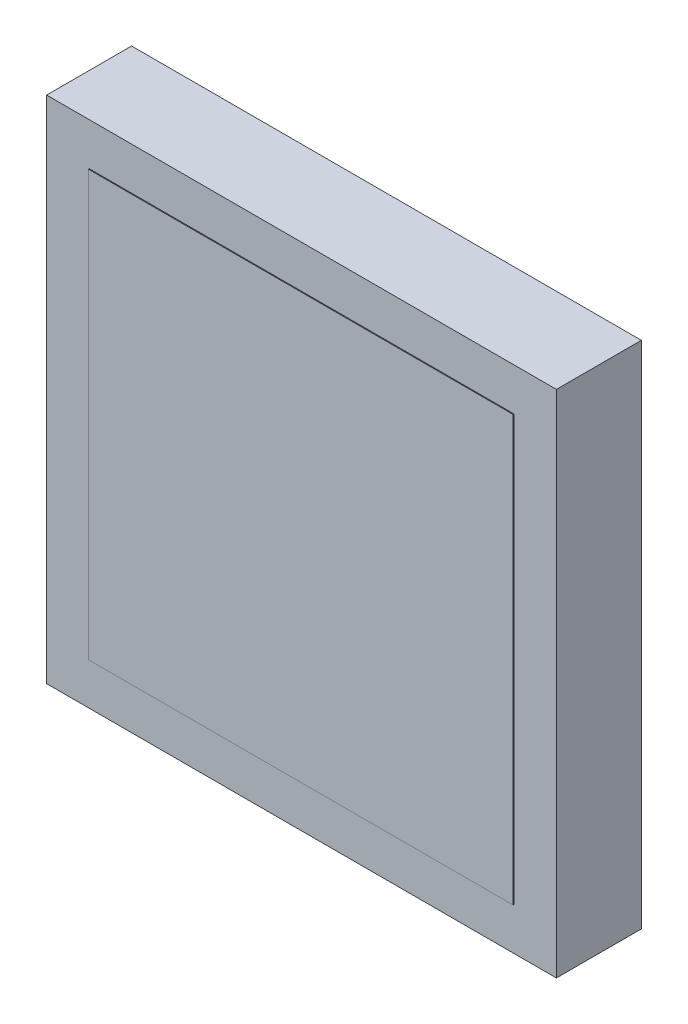
from build123d import *

# Parameters (mm, degrees)
SKETCH1_W           = 60
SKETCH1_H           = 60
BOSS_EXTRUDE1_DEPTH = 10
SKETCH2_W           = 50
SKETCH2_H           = 50
BOSS_EXTRUDE2_DEPTH = 0.1


with BuildPart() as part:
    # Sketch1 → Boss-Extrude1 (new body)
    with BuildSketch(Plane.XY):
        Rectangle(SKETCH1_W, SKETCH1_H)
    extrude(amount=BOSS_EXTRUDE1_DEPTH)

    # Sketch2 → Boss-Extrude2 (add)
    with BuildSketch(Plane.XY.offset(10)):
        Rectangle(SKETCH2_W, SKETCH2_H)
    extrude(amount=BOSS_EXTRUDE2_DEPTH)


solid = part.part
